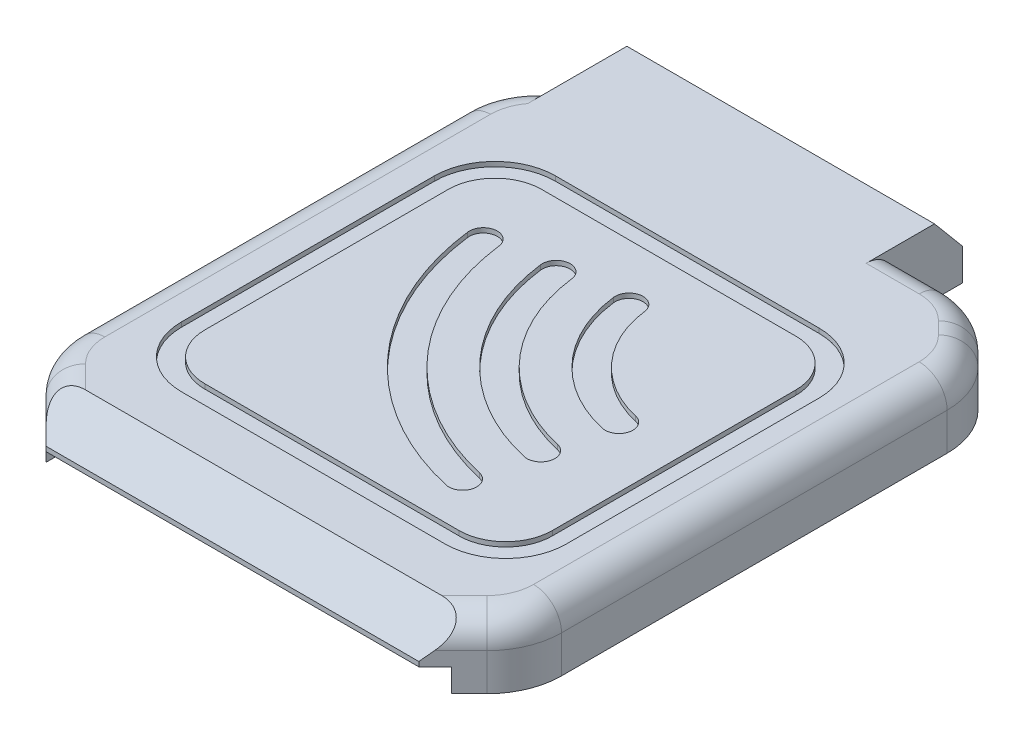
from build123d import *

# Parameters (mm, degrees)
BOSS_EXTRUDE1_DEPTH = 7
SKETCH2_W           = 43.5
SKETCH2_H           = 41.5
CUT_EXTRUDE1_DEPTH  = 6.25
BOSS_EXTRUDE2_DEPTH = 3
SKETCH4_W           = 43.25
SKETCH4_H           = 16.326941356
CUT_EXTRUDE2_DEPTH  = 2.5
SKETCH5_R           = 1.25
CUT_EXTRUDE3_DEPTH  = 6.5
SKETCH6_W           = 43.5
SKETCH6_H           = 41.5
SKETCH6_W_2         = 7
SKETCH6_H_2         = 7
BOSS_EXTRUDE3_DEPTH = 0.75
SKETCH7_W           = 41.285529239
SKETCH7_H           = 40.12964718
SKETCH7_W_2         = 37.285529239
SKETCH7_H_2         = 36.12964718
CUT_EXTRUDE4_DEPTH  = 0.5
CHAMFER1_SIZE       = 4
CHAMFER1_SIZE2      = 3.356398525
FILLET1_R           = 8
FILLET2_R           = 3
FILLET3_R           = 5
FILLET4_R           = 6.5
BOSS_EXTRUDE4_REACH = 42.311
SKETCH11_W          = 33
SKETCH11_H          = 13.592640687
CHAMFER2_SIZE       = 3.6
CHAMFER2_SIZE2      = 3.020758672
CUT_EXTRUDE7_START  = -5.5
SKETCH12_W          = 29
SKETCH12_H          = 17.85
CUT_EXTRUDE7_DEPTH  = 5.5


with BuildPart() as part:
    # Sketch1 → Boss-Extrude1 (new body)
    with BuildSketch(Plane(origin=(0, 0, 0), x_dir=(1, 0, 0), z_dir=(0, 1, 0))):
        Polygon((-26, 24), (-20, 30), (20, 30), (26, 24), (26, -24), (20, -30), (-20, -30), (-26, -24), align=None)
    extrude(amount=BOSS_EXTRUDE1_DEPTH)

    # Sketch2 → Cut-Extrude1 (cut)
    with BuildSketch(Plane.XZ):
        with Locations((1.75, 1.25)):
            Rectangle(SKETCH2_W, SKETCH2_H)
    extrude(amount=-CUT_EXTRUDE1_DEPTH, mode=Mode.SUBTRACT)

    # Sketch3 → Boss-Extrude2 (add)
    with BuildSketch(Plane.XZ.offset(-6.25)):
        Polygon((-20, 16), (-14, 22), (-20, 22), align=None)
        Polygon((-20, -13.5), (-14, -19.5), (-20, -19.5), align=None)
        Polygon((17.5, -19.5), (23.5, -19.5), (23.5, -13.5), align=None)
        Polygon((17.5, 22), (23.5, 16), (23.5, 22), align=None)
    extrude(amount=BOSS_EXTRUDE2_DEPTH)

    # Sketch4 → Cut-Extrude2 (cut)
    with BuildSketch(Plane.XZ):
        with Locations((0.125, 30.163470678)):
            Rectangle(SKETCH4_W, SKETCH4_H)
    extrude(amount=-CUT_EXTRUDE2_DEPTH, mode=Mode.SUBTRACT)

    # Sketch5 → Cut-Extrude3 (cut)
    with BuildSketch(Plane.XZ):
        with Locations(Location((-17, 25.75, 0), (0, 0, 270))):
            Circle(SKETCH5_R)
        with Locations(Location((17, 25.75, 0), (0, 0, 270))):
            Circle(SKETCH5_R)
        with Locations(Location((17, -25.75, 0), (0, 0, 270))):
            Circle(SKETCH5_R)
    extrude(amount=-CUT_EXTRUDE3_DEPTH, mode=Mode.SUBTRACT)

    # Sketch6 → Boss-Extrude3 (add)
    with BuildSketch(Plane.XZ.offset(-6.25)):
        with Locations((1.75, 1.25)):
            Rectangle(SKETCH6_W, SKETCH6_H)
        with Locations((12, -8)):
            Rectangle(SKETCH6_W_2, SKETCH6_H_2, mode=Mode.SUBTRACT)
    extrude(amount=BOSS_EXTRUDE3_DEPTH)

    # Sketch7 → Cut-Extrude4 (cut)
    with BuildSketch(Plane(origin=(0, 7, 0), x_dir=(1, 0, 0), z_dir=(0, 1, 0))):
        with Locations((0.35723538, -1.609430965)):
            Rectangle(SKETCH7_W, SKETCH7_H)
        with Locations((0.35723538, -1.609430965)):
            Rectangle(SKETCH7_W_2, SKETCH7_H_2, mode=Mode.SUBTRACT)
        with BuildLine():
            ThreePointArc((-13.273830834, 8.523353213), (-5.99678776, -7.326911946), (9.055555556, -16.136748619))
            ThreePointArc((9.055555556, -16.136748619), (10.851382953, -15.007587888), (9.722222222, -13.21176049))
            ThreePointArc((9.722222222, -13.21176049), (-3.77298213, -5.313286231), (-10.297227644, 8.897296325))
            ThreePointArc((-10.297227644, 8.897296325), (-11.972500795, 10.198626364), (-13.273830834, 8.523353213))
        make_face()
        with BuildLine():
            ThreePointArc((-6.328423391, 9.395887141), (-0.807907956, -2.628451945), (10.611111111, -9.311776318))
            ThreePointArc((10.611111111, -9.311776318), (12.406938509, -8.182615587), (11.277777778, -6.386788189))
            ThreePointArc((11.277777778, -6.386788189), (1.415897675, -0.61482623), (-3.351820202, 9.769830253))
            ThreePointArc((-3.351820202, 9.769830253), (-5.027093352, 11.071160292), (-6.328423391, 9.395887141))
        make_face()
        with BuildLine():
            ThreePointArc((0.616984051, 10.268421069), (4.380971848, 2.070008056), (12.166666667, -2.486804017))
            ThreePointArc((12.166666667, -2.486804017), (13.962494065, -1.357643286), (12.833333333, 0.438184112))
            ThreePointArc((12.833333333, 0.438184112), (6.604777479, 4.08363377), (3.593587241, 10.642364181))
            ThreePointArc((3.593587241, 10.642364181), (1.91831409, 11.94369422), (0.616984051, 10.268421069))
        make_face()
    extrude(amount=-CUT_EXTRUDE4_DEPTH, mode=Mode.SUBTRACT)

    # Chamfer1
    chamfer1_edges = [part.edges().sort_by_distance(p)[0] for p in [
        (0, 7, 30),
    ]]
    chamfer1_side = [part.faces().sort_by_distance(p)[0] for p in [
        (0, 4.75, 30),
    ]]
    chamfer(chamfer1_edges, length=CHAMFER1_SIZE, length2=CHAMFER1_SIZE2, reference=chamfer1_side[0])

    # Fillet1
    fillet1_edges = [part.edges().sort_by_distance(p)[0] for p in [
        (-26, 3.5, -24),
        (-20, 3.5, -30),
        (20, 3.5, -30),
        (26, 3.5, -24),
        (26, 3.5, 24),
        (-26, 3.5, 24),
    ]]
    fillet(fillet1_edges, radius=FILLET1_R)

    # Fillet2
    fillet2_edges = [part.edges().sort_by_distance(p)[0] for p in [
        (23.506626387, 7, 26.493373613),
        (0, 7, -30),
        (23, 7, -27),
        (-23.506626387, 7, 26.493373613),
        (26, 7, 0),
        (-23, 7, -27),
        (-26, 7, 0),
        (-25.39103626, 7, 23.74775896),
        (-25.39103626, 7, -23.74775896),
        (-19.74775896, 7, -29.39103626),
        (25.39103626, 7, 23.74775896),
        (25.39103626, 7, -23.74775896),
        (19.74775896, 7, -29.39103626),
    ]]
    fillet(fillet2_edges, radius=FILLET2_R)

    # Fillet3
    fillet3_edges = [part.edges().sort_by_distance(p)[0] for p in [
        (19, 6.75, -16.455392625),
        (-18.285529239, 6.75, -16.455392625),
        (-18.285529239, 6.75, 19.674254555),
        (19, 6.75, 19.674254555),
    ]]
    fillet(fillet3_edges, radius=FILLET3_R)

    # Fillet4
    fillet4_edges = [part.edges().sort_by_distance(p)[0] for p in [
        (-20.285529239, 6.75, 21.674254555),
        (-20.285529239, 6.75, -18.455392625),
        (21, 6.75, -18.455392625),
        (21, 6.75, 21.674254555),
    ]]
    fillet(fillet4_edges, radius=FILLET4_R)

    # Boss-Extrude4: up to this face of the body (flat: up to its plane)
    boss_extrude4_end = Plane(part.part.faces().sort_by_distance((-25.217296352, 0, 0))[0])
    # Sketch11 → Boss-Extrude4 (add, up to the picked face)
    with BuildSketch(Plane(origin=(0, 7, 0), x_dir=(1, 0, 0), z_dir=(0, 1, 0)), mode=Mode.PRIVATE) as boss_extrude4_sk1:
        with Locations((-5.5, 30.553679657)):
            Rectangle(SKETCH11_W, SKETCH11_H)
    boss_extrude4_tool1 = split(extrude(boss_extrude4_sk1.sketch, amount=-BOSS_EXTRUDE4_REACH, mode=Mode.PRIVATE), bisect_by=boss_extrude4_end, keep=Keep.BOTH, mode=Mode.PRIVATE)
    add(boss_extrude4_tool1.solids().sort_by(Axis((-5.5, 7, -30.55368), (0, -1, 0)))[0])

    # Chamfer2
    chamfer2_edges = [part.edges().sort_by_distance(p)[0] for p in [
        (-5.5, 7, -37.35),
    ]]
    chamfer2_side = [part.faces().sort_by_distance(p)[0] for p in [
        (-5.5, 3.5, -37.35),
    ]]
    chamfer(chamfer2_edges, length=CHAMFER2_SIZE, length2=CHAMFER2_SIZE2, reference=chamfer2_side[0])

    # Sketch12 → Cut-Extrude7 (cut)
    with BuildSketch(Plane.XZ.offset(CUT_EXTRUDE7_START)):
        with Locations((-5.5, -28.425)):
            Rectangle(SKETCH12_W, SKETCH12_H)
    extrude(amount=CUT_EXTRUDE7_DEPTH, mode=Mode.SUBTRACT)


solid = part.part
